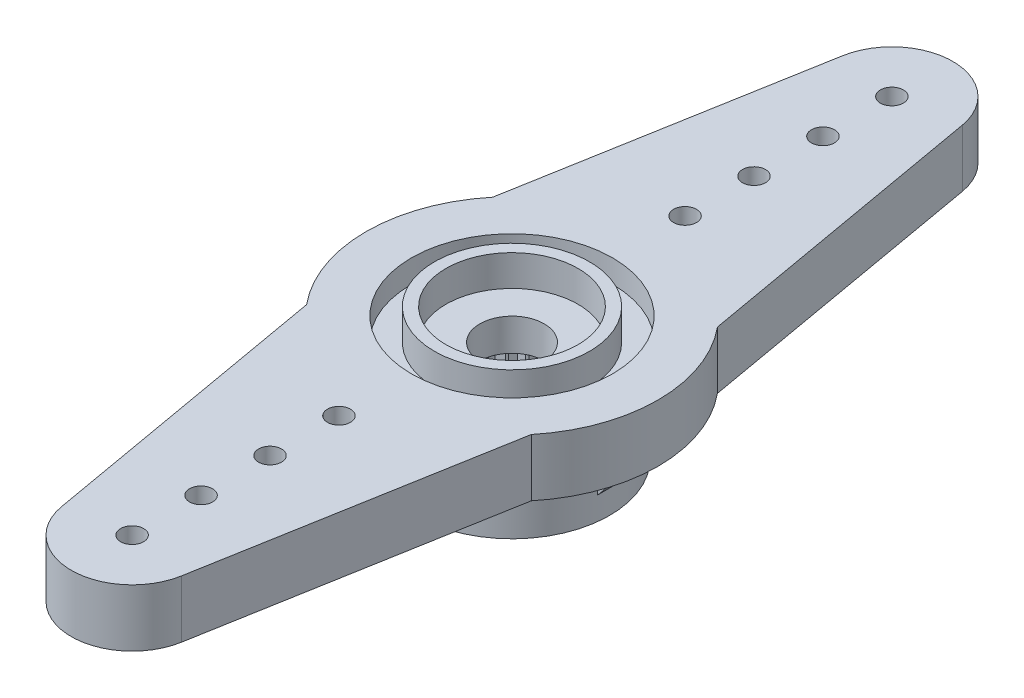
from build123d import *

# Parameters (mm, degrees)
SKETCH1_R               = 6.35
BOSS_EXTRUDE1_DEPTH     = 5.4
HORN_DEPTH              = 2.5
SKETCH4_R               = 1.4
CUT_EXTRUDE1_DEPTH      = 6.4
SKETCH5_R               = 0.5
CUT_EXTRUDE2_DEPTH      = 6.4
LPATTERN1_COUNT         = 4
LPATTERN1_PITCH         = 3
MIRROR1_COPY_1_SKETCH_R = 0.5
MIRROR1_COPY_1_DEPTH    = 6.4
MIRROR1_COPY_2_SKETCH_R = 0.5
MIRROR1_COPY_2_DEPTH    = 6.4
MIRROR1_COPY_3_SKETCH_R = 0.5
MIRROR1_COPY_3_DEPTH    = 6.4
CUT_EXTRUDE4_DEPTH      = 3
CIRPATTERN2_COUNT       = 26
SKETCH9_R               = 2.6
CUT_EXTRUDE5_DEPTH      = 3
SKETCH10_R              = 6.35
SKETCH10_R_2            = 4.25
CUT_EXTRUDE6_DEPTH      = 2.9
BOSS_EXTRUDE5_DEPTH     = 0.5
CIRPATTERN3_COUNT       = 4
SKETCH12_R              = 4.375
CUT_EXTRUDE7_DEPTH      = 1
SKETCH13_R              = 3.375
SKETCH13_R_2            = 2.875
BOSS_EXTRUDE6_DEPTH     = 1
SKETCH14_R              = 3.375
SKETCH14_R_2            = 2.875
BOSS_EXTRUDE7_DEPTH     = 0.35


with BuildPart() as part:
    # Sketch1 → Boss-Extrude1 (new body)
    with BuildSketch(Plane(origin=(0, 0, 0), x_dir=(1, 0, 0), z_dir=(0, 1, 0))):
        Circle(SKETCH1_R)
    extrude(amount=BOSS_EXTRUDE1_DEPTH)

    # Sketch2 → horn (add)
    with BuildSketch(Plane(origin=(0, 5.4, 0), x_dir=(1, 0, 0), z_dir=(0, 1, 0))):
        with BuildLine():
            Line((-2.609740545, 16.990167671), (-4.891612682, 4.049027706))
            ThreePointArc((-4.891612682, 4.049027706), (0, 6.35), (4.891612682, 4.049027706))
            Line((4.891612682, 4.049027706), (2.609740545, 16.990167671))
            ThreePointArc((2.609740545, 16.990167671), (0, 19.18), (-2.609740545, 16.990167671))
        make_face()
    horn = extrude(amount=-HORN_DEPTH)

    # Sketch4 → Cut-Extrude1 (cut, through all)
    with BuildSketch(Plane(origin=(0, 5.4, 0), x_dir=(-1, 0, 0), z_dir=(0, -1, 0))):
        Circle(SKETCH4_R)
    extrude(amount=CUT_EXTRUDE1_DEPTH, mode=Mode.SUBTRACT)

    # Sketch5 → Cut-Extrude2 (cut, through all)
    with BuildSketch(Plane(origin=(0, 0, 0), x_dir=(-1, 0, 0), z_dir=(0, -1, 0))):
        with Locations((0, 16.53)):
            Circle(SKETCH5_R)
    cut_extrude2 = extrude(amount=-CUT_EXTRUDE2_DEPTH, mode=Mode.SUBTRACT)

    # LPattern1: Cut-Extrude2 ×4
    with Locations(*[(0, 0, i * LPATTERN1_PITCH) for i in range(1, LPATTERN1_COUNT)]):
        add(cut_extrude2, mode=Mode.SUBTRACT)

    # Mirror1: horn, Cut-Extrude2 across plane
    add(horn.mirror(Plane.XY))
    add(cut_extrude2.mirror(Plane.XY), mode=Mode.SUBTRACT)

    # Mirror1 copy 1 sketch → Mirror1 copy 1 (cut, through all)
    with BuildSketch(Plane(origin=(0, 0, -3), x_dir=(-1, 0, 0), z_dir=(0, -1, 0))):
        with Locations((0, -16.53)):
            Circle(MIRROR1_COPY_1_SKETCH_R)
    extrude(amount=-MIRROR1_COPY_1_DEPTH, mode=Mode.SUBTRACT)

    # Mirror1 copy 2 sketch → Mirror1 copy 2 (cut, through all)
    with BuildSketch(Plane(origin=(0, 0, -6), x_dir=(-1, 0, 0), z_dir=(0, -1, 0))):
        with Locations((0, -16.53)):
            Circle(MIRROR1_COPY_2_SKETCH_R)
    extrude(amount=-MIRROR1_COPY_2_DEPTH, mode=Mode.SUBTRACT)

    # Mirror1 copy 3 sketch → Mirror1 copy 3 (cut, through all)
    with BuildSketch(Plane(origin=(0, 0, -9), x_dir=(-1, 0, 0), z_dir=(0, -1, 0))):
        with Locations((0, -16.53)):
            Circle(MIRROR1_COPY_3_SKETCH_R)
    extrude(amount=-MIRROR1_COPY_3_DEPTH, mode=Mode.SUBTRACT)

    # Sketch8 → Cut-Extrude4 (cut)
    with BuildSketch(Plane(origin=(0, 0, 0), x_dir=(-1, 0, 0), z_dir=(0, -1, 0))):
        with BuildLine():
            Line((0, -2.9), (0.262912611, -2.586672952))
            ThreePointArc((0.262912611, -2.586672952), (0, -2.6), (-0.262912611, -2.586672952))
            Line((-0.262912611, -2.586672952), (0, -2.9))
        make_face()
    cut_extrude4 = extrude(amount=-CUT_EXTRUDE4_DEPTH, mode=Mode.SUBTRACT)

    # CirPattern2: Cut-Extrude4 ×26 about axis
    cirpattern2_axis = Axis((0, 0, 0), (0, 1, 0))
    for i in range(1, CIRPATTERN2_COUNT):
        add(cut_extrude4.rotate(cirpattern2_axis, i * 360 / CIRPATTERN2_COUNT), mode=Mode.SUBTRACT)

    # Sketch9 → Cut-Extrude5 (cut)
    with BuildSketch(Plane(origin=(0, 0, 0), x_dir=(-1, 0, 0), z_dir=(0, -1, 0))):
        Circle(SKETCH9_R)
    extrude(amount=-CUT_EXTRUDE5_DEPTH, mode=Mode.SUBTRACT)

    # Sketch10 → Cut-Extrude6 (cut)
    with BuildSketch(Plane(origin=(0, 0, 0), x_dir=(-1, 0, 0), z_dir=(0, -1, 0))):
        Circle(SKETCH10_R)
        Circle(SKETCH10_R_2, mode=Mode.SUBTRACT)
    extrude(amount=-CUT_EXTRUDE6_DEPTH, mode=Mode.SUBTRACT)

    # Sketch11 → Boss-Extrude5 (add, symmetric)
    with BuildSketch(Plane.XY):
        Polygon((4.21, 0.99), (5.812680296, 2.9), (4.21, 2.9), (4.16, 2.9), (4.16, 0.99), align=None)
    boss_extrude5 = extrude(amount=BOSS_EXTRUDE5_DEPTH, both=True)

    # CirPattern3: Boss-Extrude5 ×4 about axis
    cirpattern3_axis = Axis((0, 0, 0), (0, 1, 0))
    for i in range(1, CIRPATTERN3_COUNT):
        add(boss_extrude5.rotate(cirpattern3_axis, i * 360 / CIRPATTERN3_COUNT))

    # Sketch12 → Cut-Extrude7 (cut)
    with BuildSketch(Plane(origin=(0, 5.4, 0), x_dir=(1, 0, 0), z_dir=(0, 1, 0))):
        Circle(SKETCH12_R)
    extrude(amount=-CUT_EXTRUDE7_DEPTH, mode=Mode.SUBTRACT)

    # Sketch13 → Boss-Extrude6 (add)
    with BuildSketch(Plane(origin=(0, 4.4, 0), x_dir=(1, 0, 0), z_dir=(0, 1, 0))):
        Circle(SKETCH13_R)
        Circle(SKETCH13_R_2, mode=Mode.SUBTRACT)
    extrude(amount=BOSS_EXTRUDE6_DEPTH)

    # Sketch14 → Boss-Extrude7 (add)
    with BuildSketch(Plane(origin=(0, 5.4, 0), x_dir=(1, 0, 0), z_dir=(0, 1, 0))):
        Circle(SKETCH14_R)
        Circle(SKETCH14_R_2, mode=Mode.SUBTRACT)
    extrude(amount=BOSS_EXTRUDE7_DEPTH)


solid = part.part
